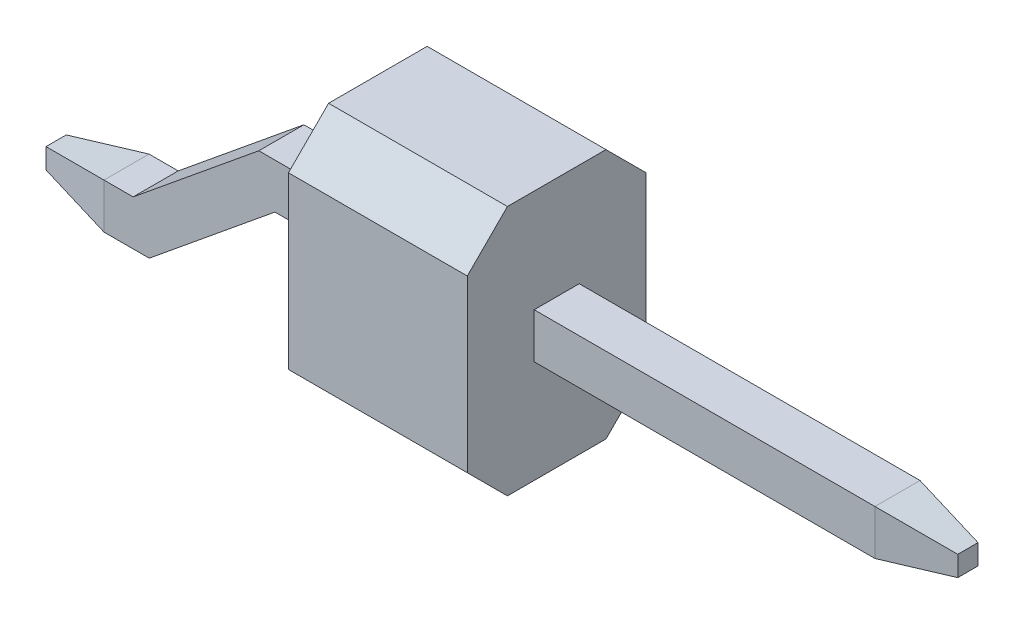
from build123d import *

# Parameters (mm, degrees)
SKETCH1_W               = 2.54
SKETCH1_H               = 2.54
BOSS_EXTRUDE1_DEPTH     = 3.56
SKETCH2_W               = 0.64
SKETCH2_H               = 0.64
BOSS_EXTRUDE2_DEPTH     = 5.84
CHAMFER1_SIZE           = 0.57
CHAMFER2_SIZE           = 1
CHAMFER2_SIZE2          = 0.176326981
CHAMFER2_PART_2_SIZE    = 1
CHAMFER2_PART_2_SIZE2   = 0.176326981
CHAMFER2_PART_3_SIZE    = 1
CHAMFER2_PART_3_SIZE2   = 0.176326981
CHAMFER2_PART_4_SIZE    = 1
CHAMFER2_PART_4_SIZE2   = 0.176326981
SKETCH3_W               = 0.64
SKETCH3_H               = 0.64
BOSS_EXTRUDE3_DEPTH     = 2.285
SKETCH4_W               = 0.64
SKETCH4_H               = 0.64
BOSS_EXTRUDE4_DEPTH     = 2.285
CHAMFER3_SIZE           = 1
CHAMFER3_SIZE2          = 0.176326981
CHAMFER3_PART_2_SIZE    = 1
CHAMFER3_PART_2_SIZE2   = 0.176326981
CHAMFER3_PART_3_SIZE    = 1
CHAMFER3_PART_3_SIZE2   = 0.176326981
CHAMFER3_PART_4_SIZE    = 1
CHAMFER3_PART_4_SIZE2   = 0.176326981
BOSS_EXTRUDE5_DEPTH     = 0.64
CUT_EXTRUDE1_DEPTH      = 1.95
CUT_EXTRUDE1_DEPTH_BACK = 2.59


with BuildPart() as part:
    # Sketch1 → Boss-Extrude1 (new body)
    with BuildSketch(Plane(origin=(0, 0, 0), x_dir=(1, 0, 0), z_dir=(0, 1, 0))):
        with Locations((1.27, 1.27)):
            Rectangle(SKETCH1_W, SKETCH1_H)
    extrude(amount=BOSS_EXTRUDE1_DEPTH)

    # Sketch2 → Boss-Extrude2 (add)
    with BuildSketch(Plane(origin=(2.54, 0, 0), x_dir=(0, 0, -1), z_dir=(1, 0, 0))):
        with Locations((1.27, 1.78)):
            Rectangle(SKETCH2_W, SKETCH2_H)
    extrude(amount=BOSS_EXTRUDE2_DEPTH)

    # Chamfer1
    chamfer1_edges = [part.edges().sort_by_distance(p)[0] for p in [
        (1.27, 3.56, -2.54),
        (1.27, 0, -2.54),
        (1.27, 0, 0),
        (1.27, 3.56, 0),
    ]]
    chamfer(chamfer1_edges, length=CHAMFER1_SIZE)

    # Chamfer2
    chamfer2_edges = [part.edges().sort_by_distance(p)[0] for p in [
        (8.38, 1.78, -0.95),
    ]]
    chamfer2_side = [part.faces().sort_by_distance(p)[0] for p in [
        (5.46, 1.78, -0.95),
    ]]
    chamfer(chamfer2_edges, length=CHAMFER2_SIZE, length2=CHAMFER2_SIZE2, reference=chamfer2_side[0])

    # Chamfer2 part 2
    chamfer2_part_2_edges = [part.edges().sort_by_distance(p)[0] for p in [
        (8.38, 1.46, -1.27),
    ]]
    chamfer2_part_2_side = [part.faces().sort_by_distance(p)[0] for p in [
        (5.46, 1.46, -1.27),
    ]]
    chamfer(chamfer2_part_2_edges, length=CHAMFER2_PART_2_SIZE, length2=CHAMFER2_PART_2_SIZE2, reference=chamfer2_part_2_side[0])

    # Chamfer2 part 3
    chamfer2_part_3_edges = [part.edges().sort_by_distance(p)[0] for p in [
        (8.38, 1.78, -1.59),
    ]]
    chamfer2_part_3_side = [part.faces().sort_by_distance(p)[0] for p in [
        (5.46, 1.78, -1.59),
    ]]
    chamfer(chamfer2_part_3_edges, length=CHAMFER2_PART_3_SIZE, length2=CHAMFER2_PART_3_SIZE2, reference=chamfer2_part_3_side[0])

    # Chamfer2 part 4
    chamfer2_part_4_edges = [part.edges().sort_by_distance(p)[0] for p in [
        (8.38, 2.1, -1.27),
    ]]
    chamfer2_part_4_side = [part.faces().sort_by_distance(p)[0] for p in [
        (5.46, 2.1, -1.27),
    ]]
    chamfer(chamfer2_part_4_edges, length=CHAMFER2_PART_4_SIZE, length2=CHAMFER2_PART_4_SIZE2, reference=chamfer2_part_4_side[0])

    # Sketch3 → Boss-Extrude3 (add)
    with BuildSketch(Plane.ZY):
        with Locations((-1.27, 1.78)):
            Rectangle(SKETCH3_W, SKETCH3_H)
    extrude(amount=BOSS_EXTRUDE3_DEPTH)



with BuildPart() as body_2:
    # Sketch4 → Boss-Extrude4 (new body)
    with BuildSketch(Plane.ZY.offset(2.285)):
        with Locations((-1.27, 0.32)):
            Rectangle(SKETCH4_W, SKETCH4_H)
    extrude(amount=BOSS_EXTRUDE4_DEPTH)

    # Chamfer3
    chamfer3_edges = [body_2.edges().sort_by_distance(p)[0] for p in [
        (-4.57, 0.32, -1.59),
    ]]
    chamfer3_side = [body_2.faces().sort_by_distance(p)[0] for p in [
        (-3.4275, 0.32, -1.59),
    ]]
    chamfer(chamfer3_edges, length=CHAMFER3_SIZE, length2=CHAMFER3_SIZE2, reference=chamfer3_side[0])

    # Chamfer3 part 2
    chamfer3_part_2_edges = [body_2.edges().sort_by_distance(p)[0] for p in [
        (-4.57, 0, -1.27),
    ]]
    chamfer3_part_2_side = [body_2.faces().sort_by_distance(p)[0] for p in [
        (-3.4275, 0, -1.27),
    ]]
    chamfer(chamfer3_part_2_edges, length=CHAMFER3_PART_2_SIZE, length2=CHAMFER3_PART_2_SIZE2, reference=chamfer3_part_2_side[0])

    # Chamfer3 part 3
    chamfer3_part_3_edges = [body_2.edges().sort_by_distance(p)[0] for p in [
        (-4.57, 0.32, -0.95),
    ]]
    chamfer3_part_3_side = [body_2.faces().sort_by_distance(p)[0] for p in [
        (-3.4275, 0.32, -0.95),
    ]]
    chamfer(chamfer3_part_3_edges, length=CHAMFER3_PART_3_SIZE, length2=CHAMFER3_PART_3_SIZE2, reference=chamfer3_part_3_side[0])

    # Chamfer3 part 4
    chamfer3_part_4_edges = [body_2.edges().sort_by_distance(p)[0] for p in [
        (-4.57, 0.64, -1.27),
    ]]
    chamfer3_part_4_side = [body_2.faces().sort_by_distance(p)[0] for p in [
        (-3.4275, 0.64, -1.27),
    ]]
    chamfer(chamfer3_part_4_edges, length=CHAMFER3_PART_4_SIZE, length2=CHAMFER3_PART_4_SIZE2, reference=chamfer3_part_4_side[0])


with BuildPart() as part_1:
    add(part.part)

    add(body_2.part)  # Boss-Extrude5 merges body 2
    # Sketch5 → Boss-Extrude5 (add)
    with BuildSketch(Plane(origin=(0, 0, -1.59), x_dir=(-1, 0, 0), z_dir=(0, 0, -1))):
        Polygon((2.285, 0.525518207), (1.1425, 1.46), (2.153367279, 1.46), (3.155901525, 0.64), (2.285, 0.64), align=None)
    extrude(amount=-BOSS_EXTRUDE5_DEPTH)

    # Sketch6 → Cut-Extrude1 (cut, two sides)
    with BuildSketch(Plane(origin=(0, 0, -1.59), x_dir=(-1, 0, 0), z_dir=(0, 0, -1))) as cut_extrude1_sk:
        Polygon((2.153367279, 1.46), (1.370901525, 2.1), (2.285, 2.1), (2.285, 1.46), align=None)
        Polygon((2.285, 0.525518207), (2.9275, 0), (2.285, 0), align=None)
    extrude(amount=CUT_EXTRUDE1_DEPTH, mode=Mode.SUBTRACT)
    extrude(cut_extrude1_sk.sketch, amount=-CUT_EXTRUDE1_DEPTH_BACK, mode=Mode.SUBTRACT)


solid = part_1.part
